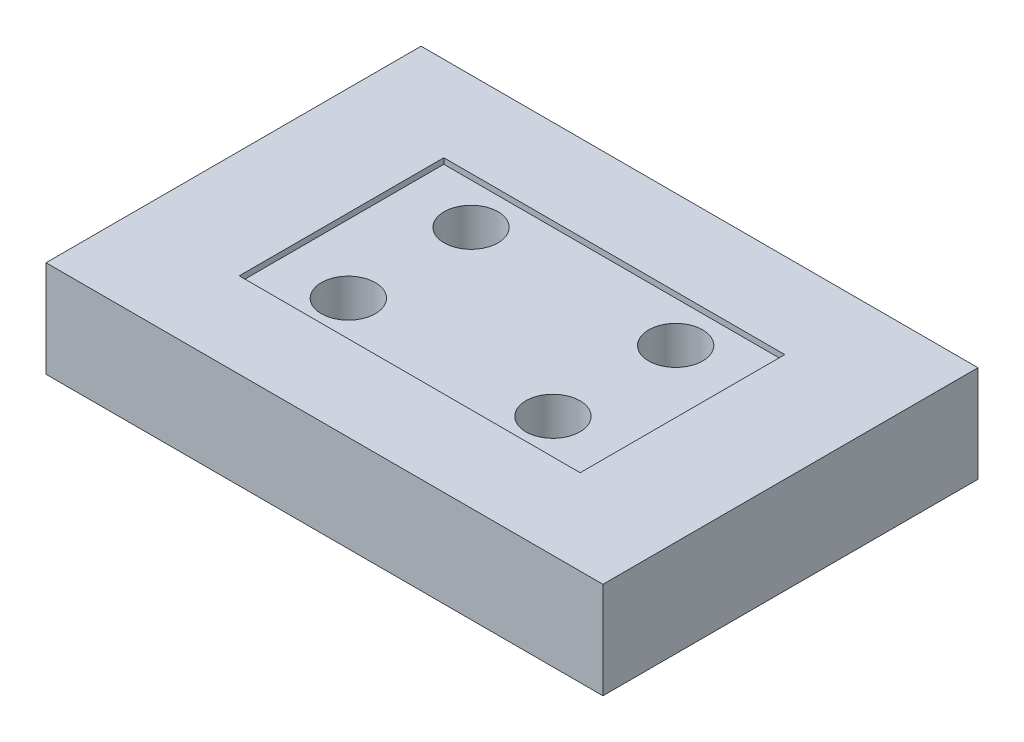
from build123d import *

# Parameters (mm, degrees)
SKETCH1_W           = 622.3
SKETCH1_H           = 419.1
BOSS_EXTRUDE1_DEPTH = 107.95
SKETCH4_R           = 30.1625
CUT_EXTRUDE3_DEPTH  = 108.95
SKETCH5_W           = 381
SKETCH5_H           = 228.6
CUT_EXTRUDE4_DEPTH  = 6.35


with BuildPart() as part:
    # Sketch1 → Boss-Extrude1 (new body)
    with BuildSketch(Plane(origin=(0, 0, 0), x_dir=(1, 0, 0), z_dir=(0, 1, 0))):
        Rectangle(SKETCH1_W, SKETCH1_H)
    extrude(amount=BOSS_EXTRUDE1_DEPTH)

    # Sketch4 → Cut-Extrude3 (cut, through all)
    with BuildSketch(Plane(origin=(0, 107.95, 0), x_dir=(1, 0, 0), z_dir=(0, 1, 0))):
        with Locations((-114.3, 68.58)):
            Circle(SKETCH4_R)
        with Locations((-114.3, -68.58)):
            Circle(SKETCH4_R)
        with Locations((114.3, 68.58)):
            Circle(SKETCH4_R)
        with Locations((114.3, -68.58)):
            Circle(SKETCH4_R)
    extrude(amount=-CUT_EXTRUDE3_DEPTH, mode=Mode.SUBTRACT)

    # Sketch5 → Cut-Extrude4 (cut)
    with BuildSketch(Plane(origin=(0, 107.95, 0), x_dir=(1, 0, 0), z_dir=(0, 1, 0))):
        Rectangle(SKETCH5_W, SKETCH5_H)
    extrude(amount=-CUT_EXTRUDE4_DEPTH, mode=Mode.SUBTRACT)


solid = part.part
